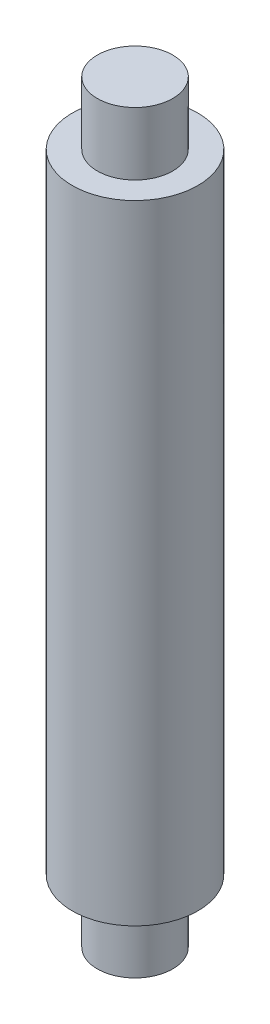
from build123d import *


with BuildPart() as part:
    # Croquis1 → Revolución1 (revolve)
    with BuildSketch(Plane.XY):
        Polygon((0, 60), (-6, 60), (-6, 50), (-10, 50), (-10, -50), (-6, -50), (-6, -60), (0, -60), align=None)
    revolve(axis=Axis((0, 0, 0), (0, 1, 0)))


solid = part.part
